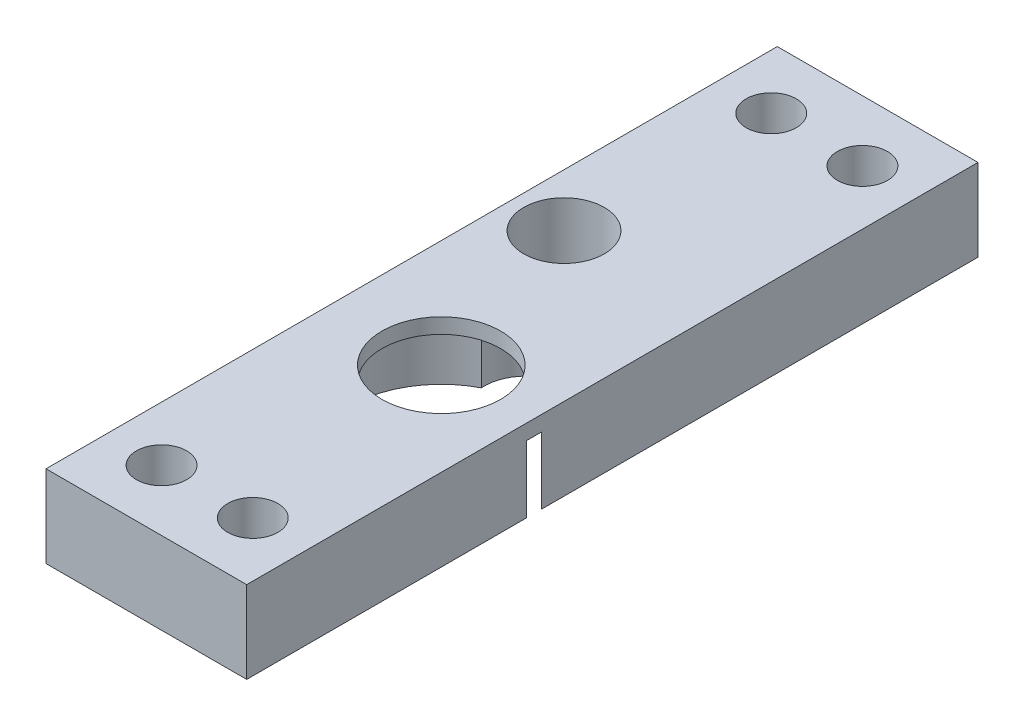
from build123d import *

# Parameters (mm, degrees)
BOSS_EXTRUDE1_DEPTH = 4.4
SKETCH2_R           = 2.65
CUT_EXTRUDE1_DEPTH  = 4
SKETCH5_W           = 13.2
SKETCH5_H           = 32.1
SKETCH5_R           = 2.65
SKETCH5_R_2         = 3.9
BOSS_EXTRUDE5_DEPTH = 1
SKETCH7_W           = 13.2
SKETCH7_H           = 8
SKETCH7_R           = 1.65
BOSS_EXTRUDE7_DEPTH = 5.4


with BuildPart() as part:
    # Sketch1 → Boss-Extrude1 (new body)
    with BuildSketch(Plane(origin=(0, 0, 0), x_dir=(1, 0, 0), z_dir=(0, 1, 0))):
        with BuildLine():
            ThreePointArc((8.894356871, 11.522321429), (11.17380815, 9.48621778), (12.179473661, 6.6))
            Line((12.179473661, 6.6), (12.2, 6.6))
            Line((12.2, 6.6), (12.2, 22.5))
            Line((12.2, 22.5), (12.2, 27.3))
            Line((12.2, 27.3), (-1, 27.3))
            Line((-1, 27.3), (-1, -4.8))
            Line((-1, -4.8), (12.2, -4.8))
            Line((12.2, -4.8), (12.2, 0))
            Line((12.2, 0), (12.2, 5.6))
            Line((12.2, 5.6), (12.179473661, 5.6))
            ThreePointArc((12.179473661, 5.6), (2.71378222, 1.02619185), (3.305643129, 11.522321429))
            ThreePointArc((3.305643129, 11.522321429), (6.1, 14.5), (8.894356871, 11.522321429))
        make_face()
    extrude(amount=BOSS_EXTRUDE1_DEPTH)

    # Sketch2 → Cut-Extrude1 (cut)
    with BuildSketch(Plane(origin=(0, 4.4, 0), x_dir=(1, 0, 0), z_dir=(0, 1, 0))):
        with Locations((2.470606111, 17.8)):
            Circle(SKETCH2_R)
    extrude(amount=-CUT_EXTRUDE1_DEPTH, mode=Mode.SUBTRACT)

    # Sketch5 → Boss-Extrude5 (add)
    with BuildSketch(Plane(origin=(0, 4.4, 0), x_dir=(1, 0, 0), z_dir=(0, 1, 0))):
        with Locations((5.6, 11.25)):
            Rectangle(SKETCH5_W, SKETCH5_H)
        with Locations((2.470606111, 17.8)):
            Circle(SKETCH5_R, mode=Mode.SUBTRACT)
        with Locations((6.1, 6.1)):
            Circle(SKETCH5_R_2, mode=Mode.SUBTRACT)
    extrude(amount=BOSS_EXTRUDE5_DEPTH)

    # Sketch7 → Boss-Extrude7 (add)
    with BuildSketch(Plane(origin=(0, 5.4, 0), x_dir=(1, 0, 0), z_dir=(0, 1, 0))):
        with Locations((5.6, -8.8)):
            Rectangle(SKETCH7_W, SKETCH7_H)
        with Locations((8.6, -8.8)):
            Circle(SKETCH7_R, mode=Mode.SUBTRACT)
        with Locations((2.6, -8.8)):
            Circle(SKETCH7_R, mode=Mode.SUBTRACT)
        with Locations((5.6, 31.3)):
            Rectangle(SKETCH7_W, SKETCH7_H)
        with Locations((8.6, 31.3)):
            Circle(SKETCH7_R, mode=Mode.SUBTRACT)
        with Locations((2.6, 31.3)):
            Circle(SKETCH7_R, mode=Mode.SUBTRACT)
    extrude(amount=-BOSS_EXTRUDE7_DEPTH)


solid = part.part
